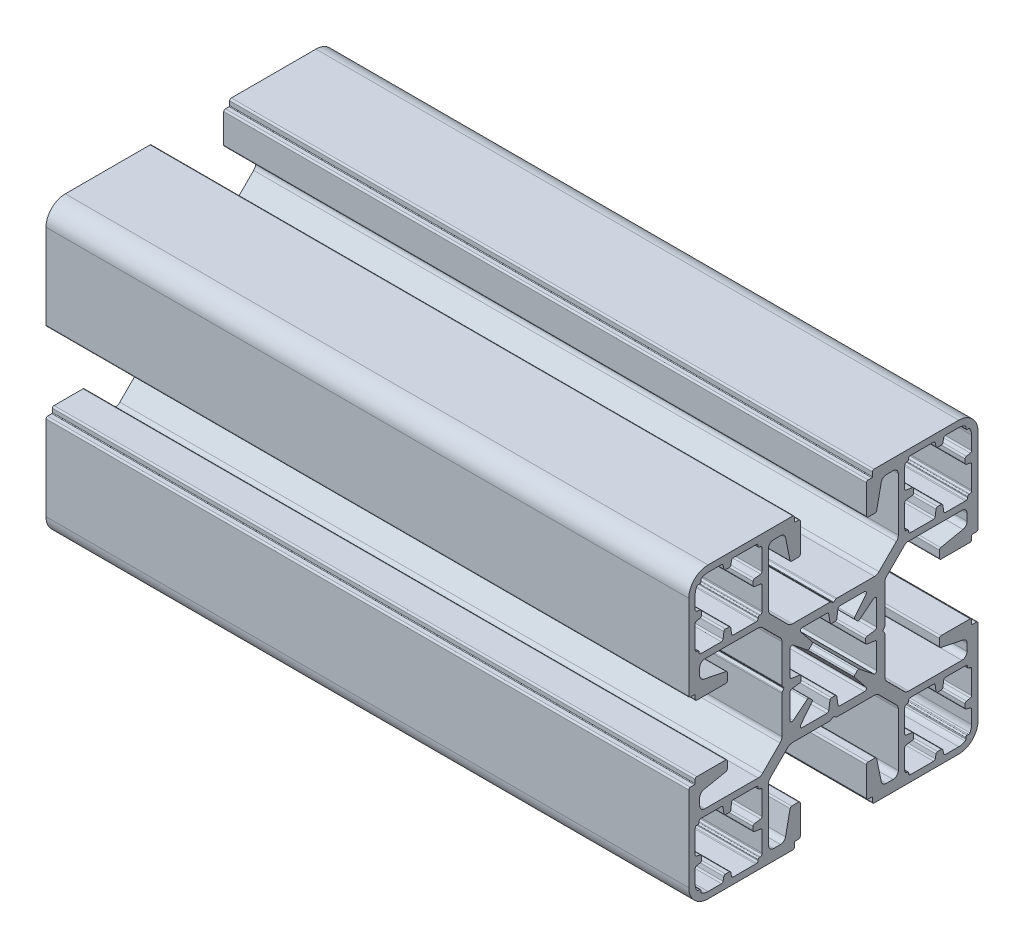
from build123d import *

# Parameters (mm, degrees)
EXTRUDE_1_DEPTH = 100


with BuildPart() as part:
    # Эскиз2 → Бобышка-Вытянуть1 (new body)
    with BuildSketch(Plane(origin=(0, 0, 0), x_dir=(0, 0, -1), z_dir=(1, 0, 0))):
        with BuildLine():
            Line((-6.32500039, -22.500001006), (-19.500001318, -22.500001006))
            ThreePointArc((-19.500001318, -22.500001006), (-21.621321734, -21.621321278), (-22.500001318, -19.500000803))
            Line((-22.500001318, -19.500000803), (-22.500000424, -6.325000112))
            ThreePointArc((-22.500000424, -6.325000112), (-22.426777247, -6.148223378), (-22.25000058, -6.075000037))
            Line((-22.25000058, -6.075000037), (-21.600001155, -6.075000037))
            ThreePointArc((-21.600001155, -6.075000037), (-21.529290476, -6.045710715), (-21.500001155, -5.975000037))
            Line((-21.500001155, -5.975000037), (-21.500001155, -5.400000112))
            ThreePointArc((-21.500001155, -5.400000112), (-21.426777686, -5.223223402), (-21.250000901, -5.150000112))
            Line((-21.250000901, -5.150000112), (-16.750000335, -5.150000112))
            ThreePointArc((-16.750000335, -5.150000112), (-16.57322364, -5.223223417), (-16.500000335, -5.400000112))
            Line((-16.500000335, -5.400000112), (-16.500000335, -6.495748386))
            ThreePointArc((-16.500000335, -6.495748386), (-16.556399432, -6.653921362), (-16.700149857, -6.740727834))
            Line((-16.700149857, -6.740727834), (-20.159522011, -7.444669972))
            ThreePointArc((-20.159522011, -7.444669972), (-20.619523384, -7.722450863), (-20.800000481, -8.228604499))
            Line((-20.800000481, -8.228604499), (-20.800000481, -9.299999719))
            ThreePointArc((-20.800000481, -9.299999719), (-20.565685743, -9.865685159), (-20.000000229, -10.099999719))
            Line((-20.000000229, -10.099999719), (-11.716294924, -10.099999719))
            ThreePointArc((-11.716294924, -10.099999719), (-11.333611491, -10.023879252), (-11.009188142, -9.8071065))
            Line((-11.009188142, -9.8071065), (-8.292894023, -7.090812381))
            ThreePointArc((-8.292894023, -7.090812381), (-8.07612127, -6.766388888), (-8.000000804, -6.383705333))
            Line((-8.000000804, -6.383705333), (-8.000000804, -0.530457045))
            ThreePointArc((-8.000000804, -0.530457045), (-7.987980309, -0.45386901), (-7.953074967, -0.384645919))
            Line((-7.953074967, -0.384645919), (-7.718770633, -0.058324445))
            ThreePointArc((-7.718770633, -0.058324445), (-7.700000383, -1.12e-07), (-7.718770633, 0.058324221))
            Line((-7.718770633, 0.058324221), (-7.953075178, 0.384645988))
            ThreePointArc((-7.953075178, 0.384645988), (-7.98798043, 0.453868976), (-8.000000804, 0.530456895))
            Line((-8.000000804, 0.530456895), (-8.000000804, 6.383705675))
            ThreePointArc((-8.000000804, 6.383705675), (-8.076121272, 6.766389107), (-8.292894023, 7.090812456))
            Line((-8.292894023, 7.090812456), (-11.009188142, 9.807106575))
            ThreePointArc((-11.009188142, 9.807106575), (-11.333611635, 10.023879329), (-11.716295191, 10.099999794))
            Line((-11.716295191, 10.099999794), (-20.000000481, 10.099999794))
            ThreePointArc((-20.000000481, 10.099999794), (-20.565685906, 9.865685219), (-20.800000481, 9.299999794))
            Line((-20.800000481, 9.299999794), (-20.800000481, 8.22860428))
            ThreePointArc((-20.800000481, 8.22860428), (-20.619523372, 7.722450758), (-20.159522011, 7.444670047))
            Line((-20.159522011, 7.444670047), (-16.700149857, 6.740727909))
            ThreePointArc((-16.700149857, 6.740727909), (-16.556399432, 6.653921437), (-16.500000335, 6.495748461))
            Line((-16.500000335, 6.495748461), (-16.500000335, 5.400000188))
            ThreePointArc((-16.500000335, 5.400000188), (-16.57322364, 5.223223492), (-16.750000335, 5.150000188))
            Line((-16.750000335, 5.150000188), (-21.250000648, 5.150000188))
            ThreePointArc((-21.250000648, 5.150000188), (-21.426777671, 5.223223313), (-21.500001155, 5.400000188))
            Line((-21.500001155, 5.400000188), (-21.500001155, 5.975000112))
            ThreePointArc((-21.500001155, 5.975000112), (-21.529290472, 6.045710786), (-21.600001143, 6.075000112))
            Line((-21.600001143, 6.075000112), (-22.250000424, 6.075000112))
            ThreePointArc((-22.250000424, 6.075000112), (-22.426777724, 6.148223379), (-22.500001318, 6.325000542))
            Line((-22.500001318, 6.325000542), (-22.500001318, 19.500001006))
            ThreePointArc((-22.500001318, 19.500001006), (-21.62132159, 21.621321422), (-19.500001115, 22.500001006))
            Line((-19.500001115, 22.500001006), (-6.325000424, 22.500000112))
            ThreePointArc((-6.325000424, 22.500000112), (-6.14822369, 22.426776935), (-6.075000349, 22.250000269))
            Line((-6.075000349, 22.250000269), (-6.075000349, 21.600000843))
            ThreePointArc((-6.075000349, 21.600000843), (-6.045711027, 21.529290164), (-5.975000349, 21.500000843))
            Line((-5.975000349, 21.500000843), (-5.400000424, 21.500000843))
            ThreePointArc((-5.400000424, 21.500000843), (-5.223223714, 21.426777374), (-5.150000424, 21.250000589))
            Line((-5.150000424, 21.250000589), (-5.150000424, 16.750000023))
            ThreePointArc((-5.150000424, 16.750000023), (-5.223223729, 16.573223328), (-5.400000424, 16.500000023))
            Line((-5.400000424, 16.500000023), (-6.495748698, 16.500000023))
            ThreePointArc((-6.495748698, 16.500000023), (-6.653921674, 16.55639912), (-6.740728146, 16.700149545))
            Line((-6.740728146, 16.700149545), (-7.444670284, 20.159521699))
            ThreePointArc((-7.444670284, 20.159521699), (-7.722451175, 20.619523072), (-8.228604811, 20.800000169))
            Line((-8.228604811, 20.800000169), (-9.300000031, 20.800000169))
            ThreePointArc((-9.300000031, 20.800000169), (-9.865685471, 20.565685431), (-10.100000031, 19.999999917))
            Line((-10.100000031, 19.999999917), (-10.100000031, 11.716294611))
            ThreePointArc((-10.100000031, 11.716294611), (-10.023879564, 11.333611179), (-9.807106812, 11.00918783))
            Line((-9.807106812, 11.00918783), (-7.090812693, 8.292893711))
            ThreePointArc((-7.090812693, 8.292893711), (-6.7663892, 8.076120958), (-6.383705645, 8.000000492))
            Line((-6.383705645, 8.000000492), (-0.530457357, 8.000000492))
            ThreePointArc((-0.530457357, 8.000000492), (-0.453869322, 7.987979997), (-0.384646231, 7.953074655))
            Line((-0.384646231, 7.953074655), (-0.058324757, 7.718770321))
            ThreePointArc((-0.058324757, 7.718770321), (-4.24e-07, 7.700000071), (0.058323909, 7.718770321))
            Line((0.058323909, 7.718770321), (0.384645676, 7.953074866))
            ThreePointArc((0.384645676, 7.953074866), (0.453868628, 7.987980106), (0.530456508, 8.000000492))
            Line((0.530456508, 8.000000492), (6.383705063, 8.000000492))
            ThreePointArc((6.383705063, 8.000000492), (6.766388495, 8.07612096), (7.090811844, 8.292893711))
            Line((7.090811844, 8.292893711), (9.807105963, 11.00918783))
            ThreePointArc((9.807105963, 11.00918783), (10.023878717, 11.333611323), (10.099999182, 11.716294879))
            Line((10.099999182, 11.716294879), (10.099999182, 20.000000169))
            ThreePointArc((10.099999182, 20.000000169), (9.865684607, 20.565685594), (9.299999182, 20.800000169))
            Line((9.299999182, 20.800000169), (8.228603668, 20.800000169))
            ThreePointArc((8.228603668, 20.800000169), (7.722450146, 20.61952306), (7.444669435, 20.159521699))
            Line((7.444669435, 20.159521699), (6.740727297, 16.700149545))
            ThreePointArc((6.740727297, 16.700149545), (6.653920825, 16.55639912), (6.495747849, 16.500000023))
            Line((6.495747849, 16.500000023), (5.399999576, 16.500000023))
            ThreePointArc((5.399999576, 16.500000023), (5.223222865, 16.573223491), (5.149999576, 16.750000276))
            Line((5.149999576, 16.750000276), (5.149999576, 21.250000843))
            ThreePointArc((5.149999576, 21.250000843), (5.22322288, 21.426777538), (5.399999576, 21.500000843))
            Line((5.399999576, 21.500000843), (5.9749995, 21.500000843))
            ThreePointArc((5.9749995, 21.500000843), (6.045710174, 21.52929016), (6.0749995, 21.600000831))
            Line((6.0749995, 21.600000831), (6.0749995, 22.250000112))
            ThreePointArc((6.0749995, 22.250000112), (6.148222767, 22.426777412), (6.32499993, 22.500001006))
            Line((6.32499993, 22.500001006), (19.500000394, 22.500001006))
            ThreePointArc((19.500000394, 22.500001006), (21.621321458, 21.621321065), (22.500001318, 19.499999968))
            Line((22.500001318, 19.499999968), (22.500000424, 6.324999277))
            ThreePointArc((22.500000424, 6.324999277), (22.426776763, 6.148223429), (22.25000058, 6.075000572))
            Line((22.25000058, 6.075000572), (21.600001155, 6.075000572))
            ThreePointArc((21.600001155, 6.075000572), (21.529290476, 6.04571125), (21.500001155, 5.975000572))
            Line((21.500001155, 5.975000572), (21.500001155, 5.400000647))
            ThreePointArc((21.500001155, 5.400000647), (21.42677785, 5.223223952), (21.250001155, 5.150000647))
            Line((21.250001155, 5.150000647), (16.750000842, 5.150000647))
            ThreePointArc((16.750000842, 5.150000647), (16.573223819, 5.223223773), (16.500000335, 5.400000647))
            Line((16.500000335, 5.400000647), (16.500000335, 6.495748921))
            ThreePointArc((16.500000335, 6.495748921), (16.556399432, 6.653921897), (16.700149857, 6.740728369))
            Line((16.700149857, 6.740728369), (20.159522011, 7.444670507))
            ThreePointArc((20.159522011, 7.444670507), (20.619523384, 7.722451398), (20.800000481, 8.228605035))
            Line((20.800000481, 8.228605035), (20.800000481, 9.300000254))
            ThreePointArc((20.800000481, 9.300000254), (20.565685743, 9.865685694), (20.000000229, 10.100000254))
            Line((20.000000229, 10.100000254), (11.716294923, 10.100000254))
            ThreePointArc((11.716294923, 10.100000254), (11.333611491, 10.023879787), (11.009188142, 9.807107035))
            Line((11.009188142, 9.807107035), (8.292894023, 7.090812916))
            ThreePointArc((8.292894023, 7.090812916), (8.07612127, 6.766389423), (8.000000804, 6.383705868))
            Line((8.000000804, 6.383705868), (8.000000804, 0.53045758))
            ThreePointArc((8.000000804, 0.53045758), (7.987980309, 0.453869545), (7.953074967, 0.384646454))
            Line((7.953074967, 0.384646454), (7.718770633, 0.05832498))
            ThreePointArc((7.718770633, 0.05832498), (7.700000383, 6.47e-07), (7.718770633, -0.058323686))
            Line((7.718770633, -0.058323686), (7.953075178, -0.384645452))
            ThreePointArc((7.953075178, -0.384645452), (7.987980418, -0.453868405), (8.000000804, -0.530456285))
            Line((8.000000804, -0.530456285), (8.000000804, -6.38370484))
            ThreePointArc((8.000000804, -6.38370484), (8.076121272, -6.766388272), (8.292894023, -7.090811621))
            Line((8.292894023, -7.090811621), (11.009188142, -9.80710574))
            ThreePointArc((11.009188142, -9.80710574), (11.333611635, -10.023878494), (11.716295191, -10.099998959))
            Line((11.716295191, -10.099998959), (20.000000481, -10.099998959))
            ThreePointArc((20.000000481, -10.099998959), (20.565685906, -9.865684384), (20.800000481, -9.299998959))
            Line((20.800000481, -9.299998959), (20.800000481, -8.228603445))
            ThreePointArc((20.800000481, -8.228603445), (20.619523372, -7.722449923), (20.159522011, -7.444669212))
            Line((20.159522011, -7.444669212), (16.700149857, -6.740727074))
            ThreePointArc((16.700149857, -6.740727074), (16.556399432, -6.653920602), (16.500000335, -6.495747626))
            Line((16.500000335, -6.495747626), (16.500000335, -5.399999353))
            ThreePointArc((16.500000335, -5.399999353), (16.573223803, -5.223222642), (16.750000588, -5.149999353))
            Line((16.750000588, -5.149999353), (21.250001155, -5.149999353))
            ThreePointArc((21.250001155, -5.149999353), (21.42677785, -5.223222657), (21.500001155, -5.399999353))
            Line((21.500001155, -5.399999353), (21.500001155, -5.974999277))
            ThreePointArc((21.500001155, -5.974999277), (21.529290472, -6.045709951), (21.600001143, -6.074999277))
            Line((21.600001143, -6.074999277), (22.250000424, -6.074999277))
            ThreePointArc((22.250000424, -6.074999277), (22.426777724, -6.148222544), (22.500001318, -6.324999707))
            Line((22.500001318, -6.324999707), (22.500001318, -19.500000171))
            ThreePointArc((22.500001318, -19.500000171), (21.621321319, -21.621321204), (19.500000205, -22.500001006))
            Line((19.500000205, -22.500001006), (6.3249995, -22.500000112))
            ThreePointArc((6.3249995, -22.500000112), (6.148222766, -22.426776935), (6.074999425, -22.250000269))
            Line((6.074999425, -22.250000269), (6.074999425, -21.600000843))
            ThreePointArc((6.074999425, -21.600000843), (6.045710103, -21.529290164), (5.974999425, -21.500000843))
            Line((5.974999425, -21.500000843), (5.3999995, -21.500000843))
            ThreePointArc((5.3999995, -21.500000843), (5.22322279, -21.426777374), (5.1499995, -21.250000589))
            Line((5.1499995, -21.250000589), (5.1499995, -16.750000023))
            ThreePointArc((5.1499995, -16.750000023), (5.223222805, -16.573223328), (5.3999995, -16.500000023))
            Line((5.3999995, -16.500000023), (6.495747774, -16.500000023))
            ThreePointArc((6.495747774, -16.500000023), (6.65392075, -16.55639912), (6.740727222, -16.700149545))
            Line((6.740727222, -16.700149545), (7.44466936, -20.159521699))
            ThreePointArc((7.44466936, -20.159521699), (7.722450251, -20.619523072), (8.228603888, -20.800000169))
            Line((8.228603888, -20.800000169), (9.299999107, -20.800000169))
            ThreePointArc((9.299999107, -20.800000169), (9.865684547, -20.565685431), (10.099999107, -19.999999917))
            Line((10.099999107, -19.999999917), (10.099999107, -11.716294611))
            ThreePointArc((10.099999107, -11.716294611), (10.02387864, -11.333611179), (9.807105888, -11.00918783))
            Line((9.807105888, -11.00918783), (7.090811769, -8.292893711))
            ThreePointArc((7.090811769, -8.292893711), (6.766388276, -8.076120958), (6.383704721, -8.000000492))
            Line((6.383704721, -8.000000492), (0.530456433, -8.000000492))
            ThreePointArc((0.530456433, -8.000000492), (0.453868398, -7.987979997), (0.384645307, -7.953074655))
            Line((0.384645307, -7.953074655), (0.058323833, -7.718770321))
            ThreePointArc((0.058323833, -7.718770321), (-5e-07, -7.700000071), (-0.058324833, -7.718770321))
            Line((-0.058324833, -7.718770321), (-0.3846466, -7.953074866))
            ThreePointArc((-0.3846466, -7.953074866), (-0.453869552, -7.987980106), (-0.530457432, -8.000000492))
            Line((-0.530457432, -8.000000492), (-6.383705987, -8.000000492))
            ThreePointArc((-6.383705987, -8.000000492), (-6.766389419, -8.07612096), (-7.090812768, -8.292893711))
            Line((-7.090812768, -8.292893711), (-9.807106887, -11.00918783))
            ThreePointArc((-9.807106887, -11.00918783), (-10.023879641, -11.333611323), (-10.100000106, -11.716294879))
            Line((-10.100000106, -11.716294879), (-10.100000106, -20.000000169))
            ThreePointArc((-10.100000106, -20.000000169), (-9.865685531, -20.565685594), (-9.300000106, -20.800000169))
            Line((-9.300000106, -20.800000169), (-8.228604592, -20.800000169))
            ThreePointArc((-8.228604592, -20.800000169), (-7.72245107, -20.61952306), (-7.444670359, -20.159521699))
            Line((-7.444670359, -20.159521699), (-6.740728221, -16.700149545))
            ThreePointArc((-6.740728221, -16.700149545), (-6.653921749, -16.55639912), (-6.495748773, -16.500000023))
            Line((-6.495748773, -16.500000023), (-5.4000005, -16.500000023))
            ThreePointArc((-5.4000005, -16.500000023), (-5.223223789, -16.573223491), (-5.1500005, -16.750000276))
            Line((-5.1500005, -16.750000276), (-5.1500005, -21.250000843))
            ThreePointArc((-5.1500005, -21.250000843), (-5.223223804, -21.426777538), (-5.4000005, -21.500000843))
            Line((-5.4000005, -21.500000843), (-5.975000424, -21.500000843))
            ThreePointArc((-5.975000424, -21.500000843), (-6.045711098, -21.52929016), (-6.075000424, -21.600000831))
            Line((-6.075000424, -21.600000831), (-6.075000424, -22.250000605))
            ThreePointArc((-6.075000424, -22.250000605), (-6.148223701, -22.426777422), (-6.32500039, -22.500001006))
        make_face()
        with BuildLine():
            Line((-17.404952078, 21.500000772), (-19.500001318, 21.500000936))
            ThreePointArc((-19.500001318, 21.500000936), (-20.006924675, 21.434691791), (-20.480741299, 21.243029638))
            ThreePointArc((-20.480741299, 21.243029638), (-20.573959041, 21.15134906), (-20.608148792, 21.025151054))
            Line((-20.608148792, 21.025151054), (-20.608148792, 20.808148511))
            ThreePointArc((-20.608148792, 20.808148511), (-20.666727436, 20.666727155), (-20.808148792, 20.608148511))
            Line((-20.808148792, 20.608148511), (-21.025151335, 20.608148511))
            ThreePointArc((-21.025151335, 20.608148511), (-21.151349341, 20.57395876), (-21.243029919, 20.480741018))
            ThreePointArc((-21.243029919, 20.480741018), (-21.434692086, 20.00692438), (-21.500001237, 19.500001006))
            Line((-21.500001237, 19.500001006), (-21.500001237, 17.404951766))
            ThreePointArc((-21.500001237, 17.404951766), (-21.443336736, 17.246454496), (-21.29903016, 17.159806575))
            Line((-21.29903016, 17.159806575), (-20.700972149, 17.040195251))
            ThreePointArc((-20.700972149, 17.040195251), (-20.556665573, 16.95354733), (-20.500001073, 16.795050061))
            Line((-20.500001073, 16.795050061), (-20.500001073, 16.204949985))
            ThreePointArc((-20.500001073, 16.204949985), (-20.556665573, 16.046452716), (-20.700972149, 15.959804794))
            Line((-20.700972149, 15.959804794), (-21.29903016, 15.840193471))
            ThreePointArc((-21.29903016, 15.840193471), (-21.443336753, 15.75354553), (-21.500001237, 15.595048228))
            Line((-21.500001237, 15.595048228), (-21.500000506, 12.100000112))
            ThreePointArc((-21.500000506, 12.100000112), (-21.494865218, 11.998786452), (-21.479512097, 11.898612315))
            ThreePointArc((-21.479512097, 11.898612315), (-21.392610885, 11.755198133), (-21.234634194, 11.698959236))
            Line((-21.234634194, 11.698959236), (-21.101041248, 11.698959236))
            ThreePointArc((-21.101041248, 11.698959236), (-20.959619892, 11.640380592), (-20.901041248, 11.498959236))
            Line((-20.901041248, 11.498959236), (-20.901041248, 11.36536629))
            ThreePointArc((-20.901041248, 11.36536629), (-20.844802352, 11.207389599), (-20.70138817, 11.120488387))
            ThreePointArc((-20.70138817, 11.120488387), (-20.601214076, 11.105135281), (-20.500000461, 11.099999998))
            Line((-20.500000461, 11.099999998), (-17.416824847, 11.099999998))
            ThreePointArc((-17.416824847, 11.099999998), (-17.253024433, 11.161136491), (-17.169337482, 11.314644604))
            Line((-17.169337482, 11.314644604), (-17.030664235, 12.285355807))
            ThreePointArc((-17.030664235, 12.285355807), (-16.946977154, 12.43886393), (-16.78317666, 12.500000413))
            Line((-16.78317666, 12.500000413), (-16.216823874, 12.500000413))
            ThreePointArc((-16.216823874, 12.500000413), (-16.053023453, 12.438863889), (-15.969336501, 12.285355756))
            Line((-15.969336501, 12.285355756), (-15.830663262, 11.314644604))
            ThreePointArc((-15.830663262, 11.314644604), (-15.746976304, 11.161136485), (-15.583175879, 11.099999998))
            Line((-15.583175879, 11.099999998), (-12.100000461, 11.100000227))
            ThreePointArc((-12.100000461, 11.100000227), (-11.998786858, 11.105135509), (-11.898612776, 11.120488614))
            ThreePointArc((-11.898612776, 11.120488614), (-11.755198594, 11.207389827), (-11.698959697, 11.365366517))
            Line((-11.698959697, 11.365366517), (-11.698959697, 11.498959463))
            ThreePointArc((-11.698959697, 11.498959463), (-11.640381053, 11.640380819), (-11.498959697, 11.698959463))
            Line((-11.498959697, 11.698959463), (-11.365366751, 11.698959463))
            ThreePointArc((-11.365366751, 11.698959463), (-11.207389998, 11.755198315), (-11.120488736, 11.898612519))
            ThreePointArc((-11.120488736, 11.898612519), (-11.105135629, 11.998786612), (-11.100000346, 12.100000227))
            Line((-11.100000346, 12.100000227), (-11.100000346, 15.583175662))
            ThreePointArc((-11.100000346, 15.583175662), (-11.16113684, 15.746976077), (-11.314644953, 15.830663028))
            Line((-11.314644953, 15.830663028), (-12.285356156, 15.969336274))
            ThreePointArc((-12.285356156, 15.969336274), (-12.438864278, 16.053023356), (-12.500000762, 16.216823849))
            Line((-12.500000762, 16.216823849), (-12.500000762, 16.783176635))
            ThreePointArc((-12.500000762, 16.783176635), (-12.438864238, 16.946977057), (-12.285356105, 17.030664008))
            Line((-12.285356105, 17.030664008), (-11.314644953, 17.169337248))
            ThreePointArc((-11.314644953, 17.169337248), (-11.161136732, 17.25302417), (-11.100000195, 17.416824654))
            Line((-11.100000195, 17.416824654), (-11.100000424, 20.500000407))
            ThreePointArc((-11.100000424, 20.500000407), (-11.105135707, 20.601214011), (-11.120488811, 20.701388093))
            ThreePointArc((-11.120488811, 20.701388093), (-11.207389956, 20.844802517), (-11.365366788, 20.901041529))
            Line((-11.365366788, 20.901041529), (-11.498959587, 20.901041529))
            ThreePointArc((-11.498959587, 20.901041529), (-11.640380943, 20.959620173), (-11.698959587, 21.101041529))
            Line((-11.698959587, 21.101041529), (-11.698959587, 21.234634475))
            ThreePointArc((-11.698959587, 21.234634475), (-11.755198484, 21.392611166), (-11.898612666, 21.479512378))
            ThreePointArc((-11.898612666, 21.479512378), (-11.998786784, 21.494865488), (-12.100000424, 21.500000772))
            Line((-12.100000424, 21.500000772), (-15.595048592, 21.500000772))
            ThreePointArc((-15.595048592, 21.500000772), (-15.753545862, 21.443336272), (-15.840193783, 21.299029696))
            Line((-15.840193783, 21.299029696), (-15.959805106, 20.700971685))
            ThreePointArc((-15.959805106, 20.700971685), (-16.046453028, 20.556665109), (-16.204950297, 20.500000609))
            Line((-16.204950297, 20.500000609), (-16.795050373, 20.500000609))
            ThreePointArc((-16.795050373, 20.500000609), (-16.953547642, 20.556665109), (-17.040195563, 20.700971685))
            Line((-17.040195563, 20.700971685), (-17.159806887, 21.299029696))
            ThreePointArc((-17.159806887, 21.299029696), (-17.246454808, 21.443336272), (-17.404952078, 21.500000772))
        make_face(mode=Mode.SUBTRACT)
        with BuildLine():
            Line((-17.404952078, -21.500000772), (-19.500001318, -21.500000936))
            ThreePointArc((-19.500001318, -21.500000936), (-20.006924675, -21.434691791), (-20.480741299, -21.243029638))
            ThreePointArc((-20.480741299, -21.243029638), (-20.573959041, -21.15134906), (-20.608148792, -21.025151054))
            Line((-20.608148792, -21.025151054), (-20.608148792, -20.808148511))
            ThreePointArc((-20.608148792, -20.808148511), (-20.666727436, -20.666727155), (-20.808148792, -20.608148511))
            Line((-20.808148792, -20.608148511), (-21.025151335, -20.608148511))
            ThreePointArc((-21.025151335, -20.608148511), (-21.151349341, -20.57395876), (-21.243029919, -20.480741018))
            ThreePointArc((-21.243029919, -20.480741018), (-21.434692086, -20.00692438), (-21.500001237, -19.500001006))
            Line((-21.500001237, -19.500001006), (-21.500001237, -17.404951766))
            ThreePointArc((-21.500001237, -17.404951766), (-21.443336736, -17.246454496), (-21.29903016, -17.159806575))
            Line((-21.29903016, -17.159806575), (-20.700972149, -17.040195251))
            ThreePointArc((-20.700972149, -17.040195251), (-20.556665573, -16.95354733), (-20.500001073, -16.795050061))
            Line((-20.500001073, -16.795050061), (-20.500001073, -16.204949985))
            ThreePointArc((-20.500001073, -16.204949985), (-20.556665573, -16.046452716), (-20.700972149, -15.959804794))
            Line((-20.700972149, -15.959804794), (-21.29903016, -15.840193471))
            ThreePointArc((-21.29903016, -15.840193471), (-21.443336753, -15.75354553), (-21.500001237, -15.595048228))
            Line((-21.500001237, -15.595048228), (-21.500000506, -12.100000112))
            ThreePointArc((-21.500000506, -12.100000112), (-21.494865218, -11.998786452), (-21.479512097, -11.898612315))
            ThreePointArc((-21.479512097, -11.898612315), (-21.392610885, -11.755198133), (-21.234634194, -11.698959236))
            Line((-21.234634194, -11.698959236), (-21.101041248, -11.698959236))
            ThreePointArc((-21.101041248, -11.698959236), (-20.959619892, -11.640380592), (-20.901041248, -11.498959236))
            Line((-20.901041248, -11.498959236), (-20.901041248, -11.36536629))
            ThreePointArc((-20.901041248, -11.36536629), (-20.844802352, -11.207389599), (-20.70138817, -11.120488387))
            ThreePointArc((-20.70138817, -11.120488387), (-20.601214076, -11.105135281), (-20.500000461, -11.099999998))
            Line((-20.500000461, -11.099999998), (-17.416824847, -11.099999998))
            ThreePointArc((-17.416824847, -11.099999998), (-17.253024433, -11.161136491), (-17.169337482, -11.314644604))
            Line((-17.169337482, -11.314644604), (-17.030664235, -12.285355807))
            ThreePointArc((-17.030664235, -12.285355807), (-16.946977154, -12.43886393), (-16.78317666, -12.500000413))
            Line((-16.78317666, -12.500000413), (-16.216823874, -12.500000413))
            ThreePointArc((-16.216823874, -12.500000413), (-16.053023453, -12.438863889), (-15.969336501, -12.285355756))
            Line((-15.969336501, -12.285355756), (-15.830663262, -11.314644604))
            ThreePointArc((-15.830663262, -11.314644604), (-15.746976304, -11.161136485), (-15.583175879, -11.099999998))
            Line((-15.583175879, -11.099999998), (-12.100000461, -11.100000227))
            ThreePointArc((-12.100000461, -11.100000227), (-11.998786858, -11.105135509), (-11.898612776, -11.120488614))
            ThreePointArc((-11.898612776, -11.120488614), (-11.755198594, -11.207389827), (-11.698959697, -11.365366517))
            Line((-11.698959697, -11.365366517), (-11.698959697, -11.498959463))
            ThreePointArc((-11.698959697, -11.498959463), (-11.640381053, -11.640380819), (-11.498959697, -11.698959463))
            Line((-11.498959697, -11.698959463), (-11.365366751, -11.698959463))
            ThreePointArc((-11.365366751, -11.698959463), (-11.207389998, -11.755198315), (-11.120488736, -11.898612519))
            ThreePointArc((-11.120488736, -11.898612519), (-11.105135629, -11.998786612), (-11.100000346, -12.100000227))
            Line((-11.100000346, -12.100000227), (-11.100000346, -15.583175662))
            ThreePointArc((-11.100000346, -15.583175662), (-11.161136773, -15.746976202), (-11.314644953, -15.83066323))
            Line((-11.314644953, -15.83066323), (-12.285356004, -15.969336455))
            ThreePointArc((-12.285356004, -15.969336455), (-12.438864127, -16.053023536), (-12.500000611, -16.21682403))
            Line((-12.500000611, -16.21682403), (-12.500000611, -16.783176816))
            ThreePointArc((-12.500000611, -16.783176816), (-12.438864086, -16.946977237), (-12.285355954, -17.030664189))
            Line((-12.285355954, -17.030664189), (-11.314644801, -17.169337428))
            ThreePointArc((-11.314644801, -17.169337428), (-11.161136682, -17.253024386), (-11.100000195, -17.416824812))
            Line((-11.100000195, -17.416824812), (-11.100000424, -20.500000407))
            ThreePointArc((-11.100000424, -20.500000407), (-11.105135707, -20.601214011), (-11.120488811, -20.701388093))
            ThreePointArc((-11.120488811, -20.701388093), (-11.207389956, -20.844802517), (-11.365366788, -20.901041529))
            Line((-11.365366788, -20.901041529), (-11.498959587, -20.901041529))
            ThreePointArc((-11.498959587, -20.901041529), (-11.640380943, -20.959620173), (-11.698959587, -21.101041529))
            Line((-11.698959587, -21.101041529), (-11.698959587, -21.234634475))
            ThreePointArc((-11.698959587, -21.234634475), (-11.755198484, -21.392611166), (-11.898612666, -21.479512378))
            ThreePointArc((-11.898612666, -21.479512378), (-11.998786784, -21.494865488), (-12.100000424, -21.500000772))
            Line((-12.100000424, -21.500000772), (-15.595048592, -21.500000772))
            ThreePointArc((-15.595048592, -21.500000772), (-15.753545862, -21.443336272), (-15.840193783, -21.299029696))
            Line((-15.840193783, -21.299029696), (-15.959805106, -20.700971685))
            ThreePointArc((-15.959805106, -20.700971685), (-16.046453028, -20.556665109), (-16.204950297, -20.500000609))
            Line((-16.204950297, -20.500000609), (-16.795050373, -20.500000609))
            ThreePointArc((-16.795050373, -20.500000609), (-16.953547642, -20.556665109), (-17.040195563, -20.700971685))
            Line((-17.040195563, -20.700971685), (-17.159806887, -21.299029696))
            ThreePointArc((-17.159806887, -21.299029696), (-17.246454808, -21.443336272), (-17.404952078, -21.500000772))
        make_face(mode=Mode.SUBTRACT)
        with BuildLine():
            Line((17.404951243, 21.500000007), (19.500000483, 21.500000171))
            ThreePointArc((19.500000483, 21.500000171), (20.006923878, 21.434691018), (20.480740535, 21.243028843))
            ThreePointArc((20.480740535, 21.243028843), (20.573958277, 21.151348265), (20.608148029, 21.025150259))
            Line((20.608148029, 21.025150259), (20.608148029, 20.808147717))
            ThreePointArc((20.608148029, 20.808147717), (20.666726672, 20.66672636), (20.808148029, 20.608147717))
            Line((20.808148029, 20.608147717), (21.025150571, 20.608147717))
            ThreePointArc((21.025150571, 20.608147717), (21.151348544, 20.57395793), (21.243029084, 20.480740183))
            ThreePointArc((21.243029084, 20.480740183), (21.434691251, 20.006923545), (21.500000401, 19.500000171))
            Line((21.500000401, 19.500000171), (21.500000401, 17.404950931))
            ThreePointArc((21.500000401, 17.404950931), (21.443335713, 17.246454026), (21.299029325, 17.159806334))
            Line((21.299029325, 17.159806334), (20.700971271, 17.040195002))
            ThreePointArc((20.700971271, 17.040195002), (20.556664695, 16.953547081), (20.500000194, 16.795049811))
            Line((20.500000194, 16.795049811), (20.500000194, 16.204949736))
            ThreePointArc((20.500000194, 16.204949736), (20.556664695, 16.046452466), (20.700971271, 15.959804545))
            Line((20.700971271, 15.959804545), (21.299029282, 15.840193222))
            ThreePointArc((21.299029282, 15.840193222), (21.443335875, 15.75354528), (21.500000358, 15.595047979))
            Line((21.500000358, 15.595047979), (21.499999628, 12.099999863))
            ThreePointArc((21.499999628, 12.099999863), (21.494864346, 11.99878626), (21.479511241, 11.898612178))
            ThreePointArc((21.479511241, 11.898612178), (21.39261005, 11.75519792), (21.234633315, 11.698958987))
            Line((21.234633315, 11.698958987), (21.101040415, 11.698958987))
            ThreePointArc((21.101040415, 11.698958987), (20.959619059, 11.640380343), (20.901040415, 11.498958987))
            Line((20.901040415, 11.498958987), (20.901040415, 11.365366041))
            ThreePointArc((20.901040415, 11.365366041), (20.844801519, 11.20738935), (20.701387337, 11.120488138))
            ThreePointArc((20.701387337, 11.120488138), (20.601213243, 11.105135031), (20.499999628, 11.099999748))
            Line((20.499999628, 11.099999748), (17.416824015, 11.099999748))
            ThreePointArc((17.416824015, 11.099999748), (17.2530236, 11.161136242), (17.169336649, 11.314644355))
            Line((17.169336649, 11.314644355), (17.030663402, 12.285355558))
            ThreePointArc((17.030663402, 12.285355558), (16.946976321, 12.43886368), (16.783175827, 12.500000164))
            Line((16.783175827, 12.500000164), (16.216823041, 12.500000164))
            ThreePointArc((16.216823041, 12.500000164), (16.05302262, 12.43886364), (15.969335668, 12.285355507))
            Line((15.969335668, 12.285355507), (15.830662429, 11.314644355))
            ThreePointArc((15.830662429, 11.314644355), (15.746975471, 11.161136236), (15.583175047, 11.099999748))
            Line((15.583175047, 11.099999748), (12.099999628, 11.099999978))
            ThreePointArc((12.099999628, 11.099999978), (11.998785968, 11.105135266), (11.89861183, 11.120488387))
            ThreePointArc((11.89861183, 11.120488387), (11.755197648, 11.207389599), (11.698958752, 11.36536629))
            Line((11.698958752, 11.36536629), (11.698958752, 11.498959236))
            ThreePointArc((11.698958752, 11.498959236), (11.640380108, 11.640380592), (11.498958752, 11.698959236))
            Line((11.498958752, 11.698959236), (11.365365806, 11.698959236))
            ThreePointArc((11.365365806, 11.698959236), (11.207389115, 11.755198133), (11.120487903, 11.898612315))
            ThreePointArc((11.120487903, 11.898612315), (11.105134796, 11.998786408), (11.099999513, 12.100000023))
            Line((11.099999513, 12.100000023), (11.099999513, 15.583175458))
            ThreePointArc((11.099999513, 15.583175458), (11.161136007, 15.746975872), (11.31464412, 15.830662824))
            Line((11.31464412, 15.830662824), (12.285355323, 15.96933607))
            ThreePointArc((12.285355323, 15.96933607), (12.438863445, 16.053023152), (12.499999929, 16.216823645))
            Line((12.499999929, 16.216823645), (12.499999929, 16.783176431))
            ThreePointArc((12.499999929, 16.783176431), (12.438863266, 16.946976589), (12.285355272, 17.030663381))
            Line((12.285355272, 17.030663381), (11.314643822, 17.169336663))
            ThreePointArc((11.314643822, 17.169336663), (11.161135703, 17.253023621), (11.099999216, 17.416824047))
            Line((11.099999216, 17.416824047), (11.099999445, 20.499999642))
            ThreePointArc((11.099999445, 20.499999642), (11.105134745, 20.601213427), (11.120487903, 20.701387685))
            ThreePointArc((11.120487903, 20.701387685), (11.207389115, 20.844801867), (11.365365806, 20.901040764))
            Line((11.365365806, 20.901040764), (11.498958752, 20.901040764))
            ThreePointArc((11.498958752, 20.901040764), (11.640380108, 20.959619408), (11.698958752, 21.101040764))
            Line((11.698958752, 21.101040764), (11.698958752, 21.23463371))
            ThreePointArc((11.698958752, 21.23463371), (11.755197648, 21.392610401), (11.89861183, 21.479511613))
            ThreePointArc((11.89861183, 21.479511613), (11.998785949, 21.494864723), (12.099999589, 21.500000007))
            Line((12.099999589, 21.500000007), (15.595047757, 21.500000007))
            ThreePointArc((15.595047757, 21.500000007), (15.753545027, 21.443335507), (15.840192948, 21.299028931))
            Line((15.840192948, 21.299028931), (15.959804271, 20.70097092))
            ThreePointArc((15.959804271, 20.70097092), (16.046452193, 20.556664344), (16.204949462, 20.499999844))
            Line((16.204949462, 20.499999844), (16.795049538, 20.499999844))
            ThreePointArc((16.795049538, 20.499999844), (16.953546807, 20.556664344), (17.040194728, 20.70097092))
            Line((17.040194728, 20.70097092), (17.159806052, 21.299028931))
            ThreePointArc((17.159806052, 21.299028931), (17.246453973, 21.443335507), (17.404951243, 21.500000007))
        make_face(mode=Mode.SUBTRACT)
        with BuildLine():
            Line((17.404951243, -21.500000007), (19.500000483, -21.500000171))
            ThreePointArc((19.500000483, -21.500000171), (20.006923878, -21.434691018), (20.480740535, -21.243028843))
            ThreePointArc((20.480740535, -21.243028843), (20.573958277, -21.151348265), (20.608148029, -21.025150259))
            Line((20.608148029, -21.025150259), (20.608148029, -20.808147717))
            ThreePointArc((20.608148029, -20.808147717), (20.666726672, -20.66672636), (20.808148029, -20.608147717))
            Line((20.808148029, -20.608147717), (21.025150571, -20.608147717))
            ThreePointArc((21.025150571, -20.608147717), (21.151348544, -20.57395793), (21.243029084, -20.480740183))
            ThreePointArc((21.243029084, -20.480740183), (21.434691251, -20.006923545), (21.500000401, -19.500000171))
            Line((21.500000401, -19.500000171), (21.500000401, -17.404950931))
            ThreePointArc((21.500000401, -17.404950931), (21.443335901, -17.246453661), (21.299029325, -17.15980574))
            Line((21.299029325, -17.15980574), (20.700971314, -17.040194416))
            ThreePointArc((20.700971314, -17.040194416), (20.556664738, -16.953546495), (20.500000238, -16.795049226))
            Line((20.500000238, -16.795049226), (20.500000238, -16.20494915))
            ThreePointArc((20.500000238, -16.20494915), (20.556664738, -16.046451881), (20.700971314, -15.959803959))
            Line((20.700971314, -15.959803959), (21.299029325, -15.840192636))
            ThreePointArc((21.299029325, -15.840192636), (21.443335889, -15.753544686), (21.500000358, -15.595047401))
            Line((21.500000358, -15.595047401), (21.499999628, -12.099999863))
            ThreePointArc((21.499999628, -12.099999863), (21.494864346, -11.99878626), (21.479511241, -11.898612178))
            ThreePointArc((21.479511241, -11.898612178), (21.39261005, -11.75519792), (21.234633315, -11.698958987))
            Line((21.234633315, -11.698958987), (21.101040415, -11.698958987))
            ThreePointArc((21.101040415, -11.698958987), (20.959619059, -11.640380343), (20.901040415, -11.498958987))
            Line((20.901040415, -11.498958987), (20.901040415, -11.365366041))
            ThreePointArc((20.901040415, -11.365366041), (20.844801519, -11.20738935), (20.701387337, -11.120488138))
            ThreePointArc((20.701387337, -11.120488138), (20.601213243, -11.105135031), (20.499999628, -11.099999748))
            Line((20.499999628, -11.099999748), (17.416824015, -11.099999748))
            ThreePointArc((17.416824015, -11.099999748), (17.2530236, -11.161136242), (17.169336649, -11.314644355))
            Line((17.169336649, -11.314644355), (17.030663402, -12.285355558))
            ThreePointArc((17.030663402, -12.285355558), (16.946976321, -12.43886368), (16.783175827, -12.500000164))
            Line((16.783175827, -12.500000164), (16.216823041, -12.500000164))
            ThreePointArc((16.216823041, -12.500000164), (16.05302262, -12.43886364), (15.969335668, -12.285355507))
            Line((15.969335668, -12.285355507), (15.830662429, -11.314644355))
            ThreePointArc((15.830662429, -11.314644355), (15.746975471, -11.161136236), (15.583175047, -11.099999748))
            Line((15.583175047, -11.099999748), (12.099999628, -11.099999978))
            ThreePointArc((12.099999628, -11.099999978), (11.998785968, -11.105135266), (11.89861183, -11.120488387))
            ThreePointArc((11.89861183, -11.120488387), (11.755197648, -11.207389599), (11.698958752, -11.36536629))
            Line((11.698958752, -11.36536629), (11.698958752, -11.498959236))
            ThreePointArc((11.698958752, -11.498959236), (11.640380108, -11.640380592), (11.498958752, -11.698959236))
            Line((11.498958752, -11.698959236), (11.365365806, -11.698959236))
            ThreePointArc((11.365365806, -11.698959236), (11.207389115, -11.755198133), (11.120487903, -11.898612315))
            ThreePointArc((11.120487903, -11.898612315), (11.105134796, -11.998786408), (11.099999513, -12.100000023))
            Line((11.099999513, -12.100000023), (11.099999513, -15.583175458))
            ThreePointArc((11.099999513, -15.583175458), (11.161136007, -15.746975872), (11.31464412, -15.830662824))
            Line((11.31464412, -15.830662824), (12.285355323, -15.96933607))
            ThreePointArc((12.285355323, -15.96933607), (12.438863246, -16.053023223), (12.499999632, -16.216823603))
            Line((12.499999632, -16.216823603), (12.499999632, -16.783176051))
            ThreePointArc((12.499999632, -16.783176051), (12.438863107, -16.946976472), (12.285354974, -17.030663423))
            Line((12.285354974, -17.030663423), (11.314643822, -17.169336663))
            ThreePointArc((11.314643822, -17.169336663), (11.161135703, -17.253023621), (11.099999216, -17.416824047))
            Line((11.099999216, -17.416824047), (11.099999445, -20.499999642))
            ThreePointArc((11.099999445, -20.499999642), (11.105134745, -20.601213427), (11.120487903, -20.701387685))
            ThreePointArc((11.120487903, -20.701387685), (11.207389115, -20.844801867), (11.365365806, -20.901040764))
            Line((11.365365806, -20.901040764), (11.498958752, -20.901040764))
            ThreePointArc((11.498958752, -20.901040764), (11.640380108, -20.959619408), (11.698958752, -21.101040764))
            Line((11.698958752, -21.101040764), (11.698958752, -21.23463371))
            ThreePointArc((11.698958752, -21.23463371), (11.755197648, -21.392610401), (11.89861183, -21.479511613))
            ThreePointArc((11.89861183, -21.479511613), (11.998785949, -21.494864723), (12.099999589, -21.500000007))
            Line((12.099999589, -21.500000007), (15.595047757, -21.500000007))
            ThreePointArc((15.595047757, -21.500000007), (15.753545027, -21.443335507), (15.840192948, -21.299028931))
            Line((15.840192948, -21.299028931), (15.959804271, -20.70097092))
            ThreePointArc((15.959804271, -20.70097092), (16.046452193, -20.556664344), (16.204949462, -20.499999844))
            Line((16.204949462, -20.499999844), (16.795049538, -20.499999844))
            ThreePointArc((16.795049538, -20.499999844), (16.953546807, -20.556664344), (17.040194728, -20.70097092))
            Line((17.040194728, -20.70097092), (17.159806052, -21.299028931))
            ThreePointArc((17.159806052, -21.299028931), (17.246453973, -21.443335507), (17.404951243, -21.500000007))
        make_face(mode=Mode.SUBTRACT)
        with BuildLine():
            Line((-4.842251904, -6.740000099), (-1.009977714, -6.740000099))
            ThreePointArc((-1.009977714, -6.740000099), (-0.813508369, -6.666715332), (-0.713027093, -6.482665411))
            Line((-0.713027093, -6.482665411), (-0.53081163, -5.214445574))
            ThreePointArc((-0.53081163, -5.214445574), (-0.447077233, -5.061070639), (-0.28335278, -5))
            Line((-0.28335278, -5), (0.283351811, -5))
            ThreePointArc((0.283351811, -5), (0.447076265, -5.061070639), (0.530810662, -5.214445574))
            Line((0.530810662, -5.214445574), (0.713026124, -6.482665411))
            ThreePointArc((0.713026124, -6.482665411), (0.813507401, -6.666715332), (1.009976745, -6.740000099))
            Line((1.009976745, -6.740000099), (4.842250936, -6.740000099))
            ThreePointArc((4.842250936, -6.740000099), (5.112704328, -6.569826764), (5.076331348, -6.252366518))
            Line((5.076331348, -6.252366518), (3.322065484, -4.063849541))
            ThreePointArc((3.322065484, -4.063849541), (3.267508439, -3.893783085), (3.340355799, -3.730711528))
            Line((3.340355799, -3.730711528), (3.730711044, -3.340356284))
            ThreePointArc((3.730711044, -3.340356284), (3.893782601, -3.267508923), (4.063849057, -3.322065969))
            Line((4.063849057, -3.322065969), (6.252366034, -5.076331833))
            ThreePointArc((6.252366034, -5.076331833), (6.56982628, -5.112704812), (6.739999615, -4.84225142))
            Line((6.739999615, -4.84225142), (6.739999615, -1.009977229))
            ThreePointArc((6.739999615, -1.009977229), (6.666714848, -0.813507885), (6.482664926, -0.713026609))
            Line((6.482664926, -0.713026609), (5.214445089, -0.530811146))
            ThreePointArc((5.214445089, -0.530811146), (5.061070155, -0.447076749), (4.999999516, -0.283352295))
            Line((4.999999516, -0.283352295), (4.999999516, 0.283352295))
            ThreePointArc((4.999999516, 0.283352295), (5.061070155, 0.447076749), (5.214445089, 0.530811146))
            Line((5.214445089, 0.530811146), (6.482664926, 0.713026609))
            ThreePointArc((6.482664926, 0.713026609), (6.666714848, 0.813507885), (6.739999615, 1.009977229))
            Line((6.739999615, 1.009977229), (6.739999615, 4.84225142))
            ThreePointArc((6.739999615, 4.84225142), (6.56982628, 5.112704812), (6.252366034, 5.076331833))
            Line((6.252366034, 5.076331833), (4.063849057, 3.322065969))
            ThreePointArc((4.063849057, 3.322065969), (3.893782601, 3.267508923), (3.730711044, 3.340356284))
            Line((3.730711044, 3.340356284), (3.340355799, 3.730711528))
            ThreePointArc((3.340355799, 3.730711528), (3.267508439, 3.893783085), (3.322065484, 4.063849541))
            Line((3.322065484, 4.063849541), (5.076331348, 6.252366518))
            ThreePointArc((5.076331348, 6.252366518), (5.112704328, 6.569826764), (4.842250936, 6.740000099))
            Line((4.842250936, 6.740000099), (1.009976745, 6.740000099))
            ThreePointArc((1.009976745, 6.740000099), (0.813507401, 6.666715332), (0.713026124, 6.482665411))
            Line((0.713026124, 6.482665411), (0.530810662, 5.214445574))
            ThreePointArc((0.530810662, 5.214445574), (0.447076265, 5.061070639), (0.283351811, 5))
            Line((0.283351811, 5), (-0.28335278, 5))
            ThreePointArc((-0.28335278, 5), (-0.447077233, 5.061070639), (-0.53081163, 5.214445574))
            Line((-0.53081163, 5.214445574), (-0.713027093, 6.482665411))
            ThreePointArc((-0.713027093, 6.482665411), (-0.813508369, 6.666715332), (-1.009977714, 6.740000099))
            Line((-1.009977714, 6.740000099), (-4.842251904, 6.740000099))
            ThreePointArc((-4.842251904, 6.740000099), (-5.112705296, 6.569826764), (-5.076332317, 6.252366518))
            Line((-5.076332317, 6.252366518), (-3.322066453, 4.063849541))
            ThreePointArc((-3.322066453, 4.063849541), (-3.267509407, 3.893783085), (-3.340356768, 3.730711528))
            Line((-3.340356768, 3.730711528), (-3.730712012, 3.340356284))
            ThreePointArc((-3.730712012, 3.340356284), (-3.893783569, 3.267508923), (-4.063850025, 3.322065969))
            Line((-4.063850025, 3.322065969), (-6.252367003, 5.076331833))
            ThreePointArc((-6.252367003, 5.076331833), (-6.569827248, 5.112704812), (-6.740000583, 4.84225142))
            Line((-6.740000583, 4.84225142), (-6.740000583, 1.009977229))
            ThreePointArc((-6.740000583, 1.009977229), (-6.666715816, 0.813507885), (-6.482665895, 0.713026609))
            Line((-6.482665895, 0.713026609), (-5.214446058, 0.530811146))
            ThreePointArc((-5.214446058, 0.530811146), (-5.061071124, 0.447076749), (-5.000000484, 0.283352295))
            Line((-5.000000484, 0.283352295), (-5.000000484, -0.283352295))
            ThreePointArc((-5.000000484, -0.283352295), (-5.061071124, -0.447076749), (-5.214446058, -0.530811146))
            Line((-5.214446058, -0.530811146), (-6.482665895, -0.713026609))
            ThreePointArc((-6.482665895, -0.713026609), (-6.666715816, -0.813507885), (-6.740000583, -1.009977229))
            Line((-6.740000583, -1.009977229), (-6.740000583, -4.84225142))
            ThreePointArc((-6.740000583, -4.84225142), (-6.569827248, -5.112704812), (-6.252367003, -5.076331833))
            Line((-6.252367003, -5.076331833), (-4.063850025, -3.322065969))
            ThreePointArc((-4.063850025, -3.322065969), (-3.893783569, -3.267508923), (-3.730712012, -3.340356284))
            Line((-3.730712012, -3.340356284), (-3.340356768, -3.730711528))
            ThreePointArc((-3.340356768, -3.730711528), (-3.267509407, -3.893783085), (-3.322066453, -4.063849541))
            Line((-3.322066453, -4.063849541), (-5.076332317, -6.252366518))
            ThreePointArc((-5.076332317, -6.252366518), (-5.112705296, -6.569826764), (-4.842251904, -6.740000099))
        make_face(mode=Mode.SUBTRACT)
    extrude(amount=-EXTRUDE_1_DEPTH)


solid = part.part
